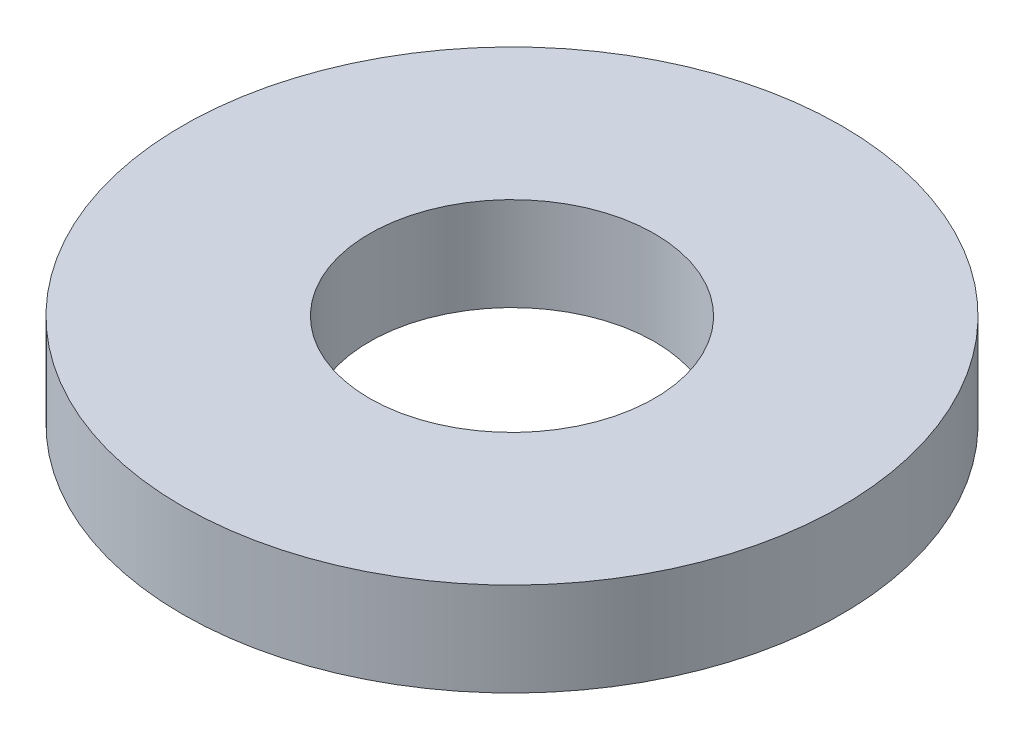
from build123d import *

# Parameters (mm, degrees)
SKETCH_1_R      = 3.525
SKETCH_1_R_2    = 1.525
EXTRUDE_1_DEPTH = 1


with BuildPart() as part:
    # 草图1 → 凸台-拉伸1 (new body)
    with BuildSketch(Plane(origin=(0, 0, 0), x_dir=(1, 0, 0), z_dir=(0, 1, 0))):
        Circle(SKETCH_1_R)
        Circle(SKETCH_1_R_2, mode=Mode.SUBTRACT)
    extrude(amount=EXTRUDE_1_DEPTH)


solid = part.part
